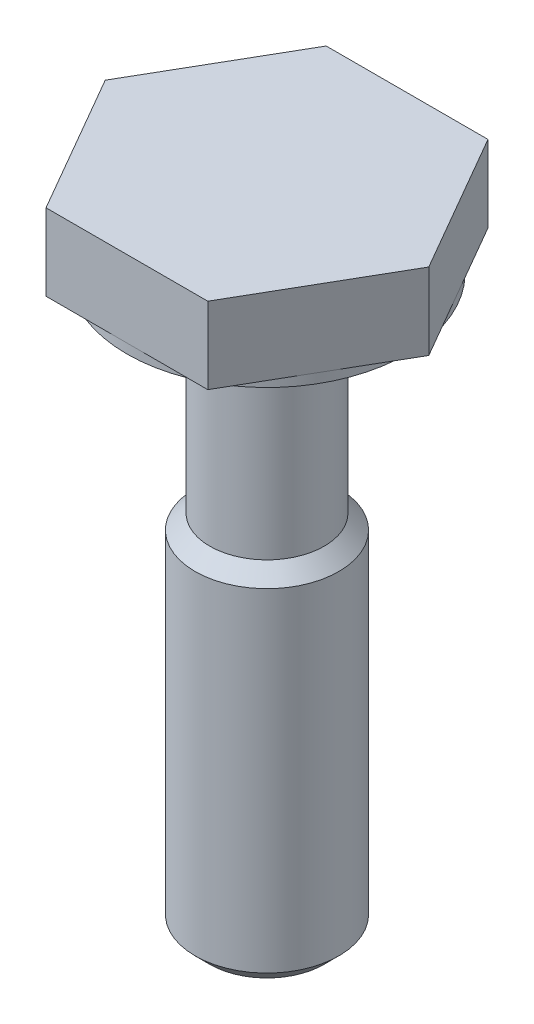
from build123d import *

# Parameters (mm, degrees)
BOSS_EXTRUDE1_DEPTH = 1.6


with BuildPart() as part:
    # Эскиз1 → Повернуть1 (revolve)
    with BuildSketch(Plane.XY):
        Polygon((-2.875, 1.8), (0, 1.8), (0, -11.24), (-0.65, -11.9), (-1.195, -11.9), (-1.5, -11.595), (-1.5, -4.645), (-1.195, -4.34), (-1.195, 1), (-2.5, 1), (-2.5, 0), (-2.925, 0), (-2.925, 1.75), align=None)
    revolve(axis=Axis((0, 0, 0), (0, -1, 0)))

    # Sketch1 → Boss-Extrude1 (add)
    with BuildSketch(Plane(origin=(0, 1.8, 0), x_dir=(1, 0, 0), z_dir=(0, 1, 0))):
        Polygon((1.688749537, 2.925), (-1.688749537, 2.925), (-3.377499075, 0), (-1.688749537, -2.925), (1.688749537, -2.925), (3.377499075, 0), align=None)
    extrude(amount=-BOSS_EXTRUDE1_DEPTH)


solid = part.part
